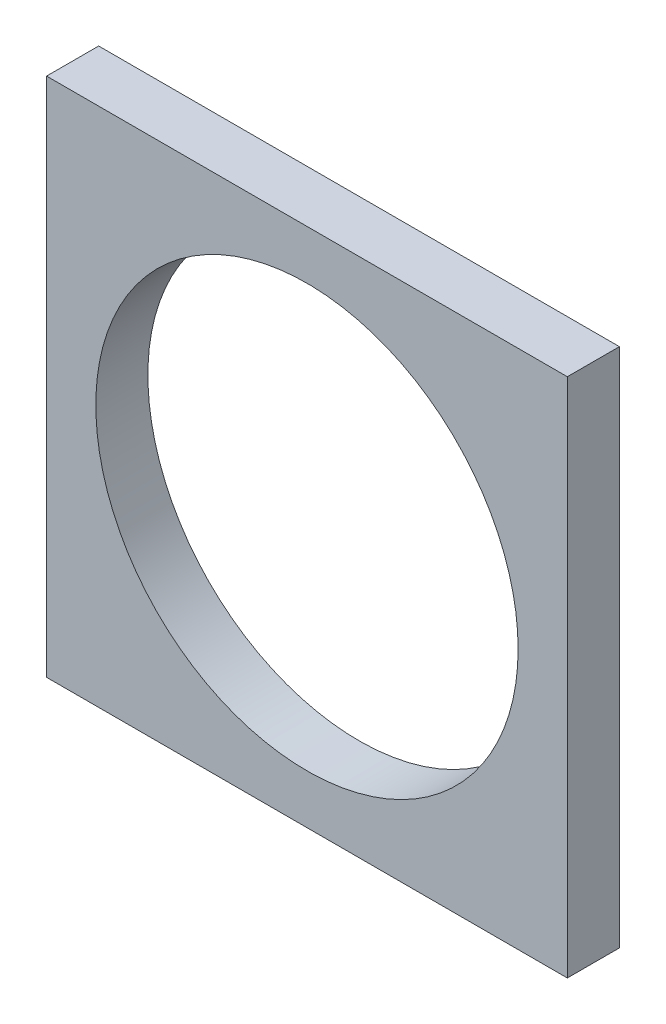
from build123d import *

# Parameters (mm, degrees)
SKETCH1_W           = 127
SKETCH1_H           = 127
BOSS_EXTRUDE1_DEPTH = 12.7
CUT_EXTRUDE1_REACH  = 14.7
SKETCH2_R           = 51.5


with BuildPart() as part:
    # Sketch1 → Boss-Extrude1 (new body)
    with BuildSketch(Plane.XY):
        Rectangle(SKETCH1_W, SKETCH1_H)
    extrude(amount=BOSS_EXTRUDE1_DEPTH)

    # Sketch2 → Cut-Extrude1 (cut, up to next)
    with BuildSketch(Plane.XY.offset(12.7), mode=Mode.PRIVATE) as cut_extrude1_sk1:
        Circle(SKETCH2_R)
    cut_extrude1_tool1 = extrude(cut_extrude1_sk1.sketch, amount=-CUT_EXTRUDE1_REACH, mode=Mode.PRIVATE) & part.part
    add(cut_extrude1_tool1.solids().sort_by_distance((0, 0, 12.7))[0], mode=Mode.SUBTRACT)


solid = part.part
